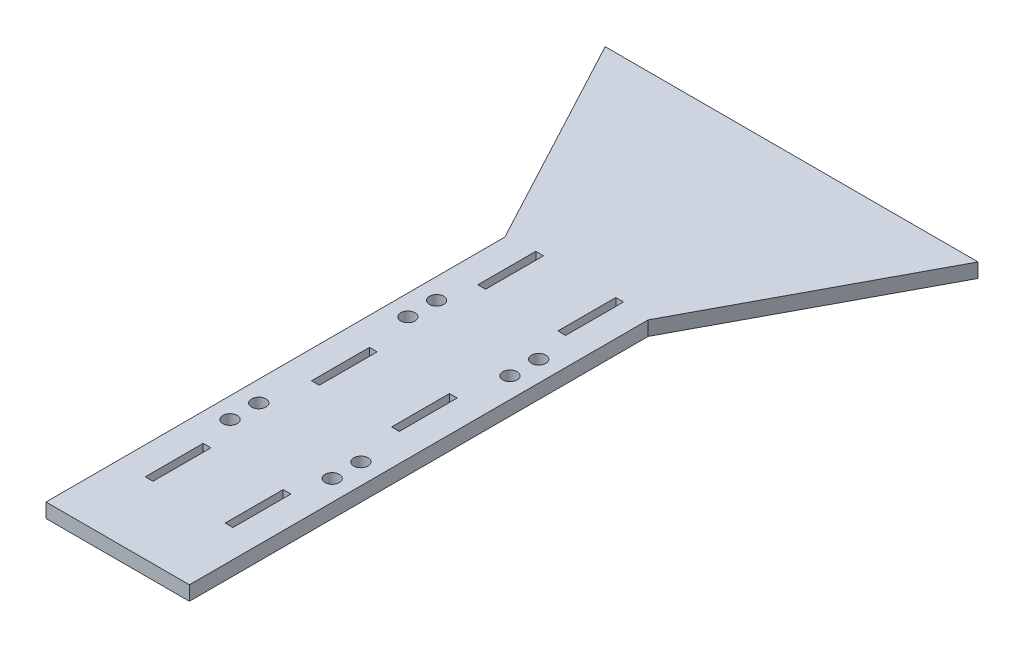
from build123d import *

# Parameters (mm, degrees)
BOSS_EXTRUDE1_DEPTH = 6.35
SKETCH2_W           = 3.429
SKETCH2_H           = 25.654
CUT_EXTRUDE1_DEPTH  = 7.35
SKETCH3_R           = 3.175
CUT_EXTRUDE2_DEPTH  = 7.35


with BuildPart() as part:
    # Sketch1 → Boss-Extrude1 (new body)
    with BuildSketch(Plane(origin=(0, 0, 0), x_dir=(1, 0, 0), z_dir=(0, 1, 0))):
        Polygon((-31.75, 0), (31.75, 0), (31.75, 203.2), (82.55, 298.45), (-82.55, 298.45), (-31.75, 203.2), align=None)
    extrude(amount=BOSS_EXTRUDE1_DEPTH)

    # Sketch2 → Cut-Extrude1 (cut, through all)
    with BuildSketch(Plane(origin=(0, 6.35, 0), x_dir=(1, 0, 0), z_dir=(0, 1, 0))):
        with Locations((-17.7165, 44.45)):
            Rectangle(SKETCH2_W, SKETCH2_H)
        with Locations((-17.7165, 118.11)):
            Rectangle(SKETCH2_W, SKETCH2_H)
        with Locations((-17.7165, 191.77)):
            Rectangle(SKETCH2_W, SKETCH2_H)
        with Locations((17.7165, 191.77)):
            Rectangle(SKETCH2_W, SKETCH2_H)
        with Locations((17.7165, 118.11)):
            Rectangle(SKETCH2_W, SKETCH2_H)
        with Locations((17.7165, 44.45)):
            Rectangle(SKETCH2_W, SKETCH2_H)
    extrude(amount=-CUT_EXTRUDE1_DEPTH, mode=Mode.SUBTRACT)

    # Sketch3 → Cut-Extrude2 (cut, through all)
    with BuildSketch(Plane(origin=(0, 6.35, 0), x_dir=(1, 0, 0), z_dir=(0, 1, 0))):
        with Locations((-22.606, 163.83)):
            Circle(SKETCH3_R)
        with Locations((-22.606, 151.13)):
            Circle(SKETCH3_R)
        with Locations((22.606, 151.13)):
            Circle(SKETCH3_R)
        with Locations((22.606, 163.83)):
            Circle(SKETCH3_R)
        with Locations((22.606, 85.09)):
            Circle(SKETCH3_R)
        with Locations((22.606, 72.39)):
            Circle(SKETCH3_R)
        with Locations((-22.606, 72.39)):
            Circle(SKETCH3_R)
        with Locations((-22.606, 85.09)):
            Circle(SKETCH3_R)
    extrude(amount=-CUT_EXTRUDE2_DEPTH, mode=Mode.SUBTRACT)


solid = part.part
